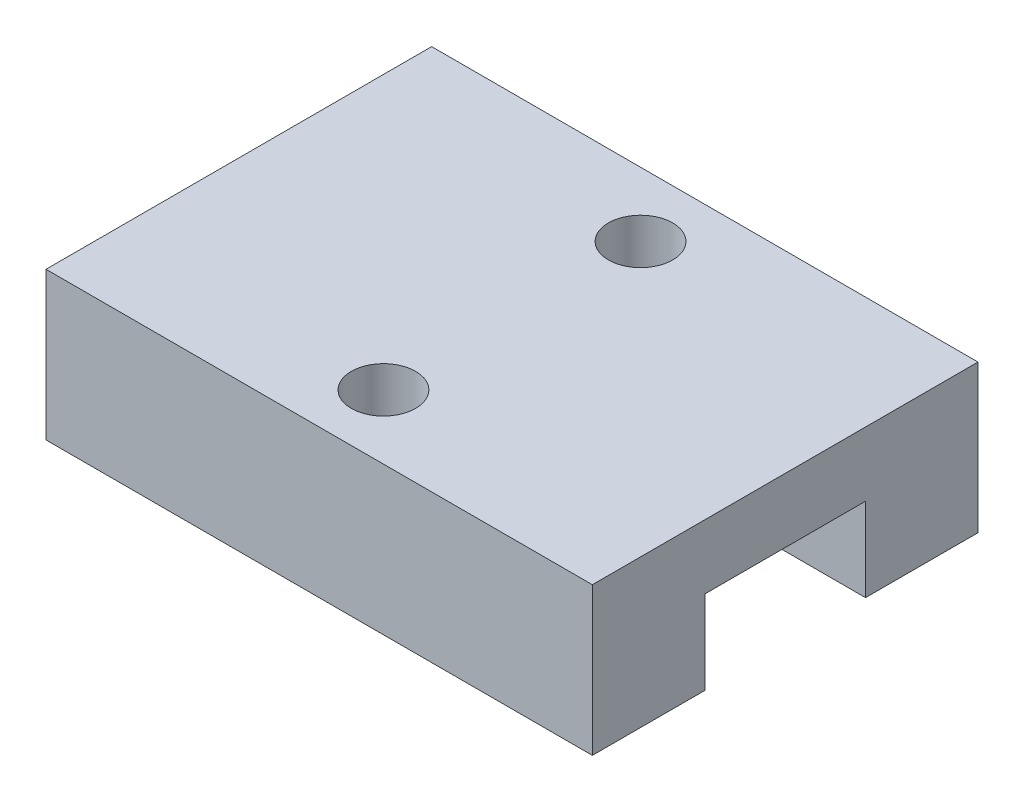
from build123d import *

# Parameters (mm, degrees)
SKETCH_1_W          = 17
SKETCH_1_H          = 12
EXTRUDE_1_DEPTH     = 4.6
SKETCH_3_W          = 17
SKETCH_3_H          = 5
CUT_EXTRUDE_1_DEPTH = 2.6
SKETCH_4_R          = 1
CUT_EXTRUDE_2_DEPTH = 2


with BuildPart() as part:
    # 스케치1 → 보스-돌출1 (new body)
    with BuildSketch(Plane(origin=(0, 0, 0), x_dir=(1, 0, 0), z_dir=(0, 1, 0))):
        Rectangle(SKETCH_1_W, SKETCH_1_H)
    extrude(amount=EXTRUDE_1_DEPTH)

    # 스케치3 → 컷-돌출1 (cut)
    with BuildSketch(Plane(origin=(0, 2.6, 0), x_dir=(1, 0, 0), z_dir=(0, 1, 0))):
        Rectangle(SKETCH_3_W, SKETCH_3_H)
    extrude(amount=-CUT_EXTRUDE_1_DEPTH, mode=Mode.SUBTRACT)

    # 스케치4 → 컷-돌출2 (cut)
    with BuildSketch(Plane(origin=(0, 4.6, 0), x_dir=(1, 0, 0), z_dir=(0, 1, 0))):
        with Locations((0, 4)):
            Circle(SKETCH_4_R)
        with Locations((0, -4)):
            Circle(SKETCH_4_R)
    extrude(amount=-CUT_EXTRUDE_2_DEPTH, mode=Mode.SUBTRACT)


solid = part.part
